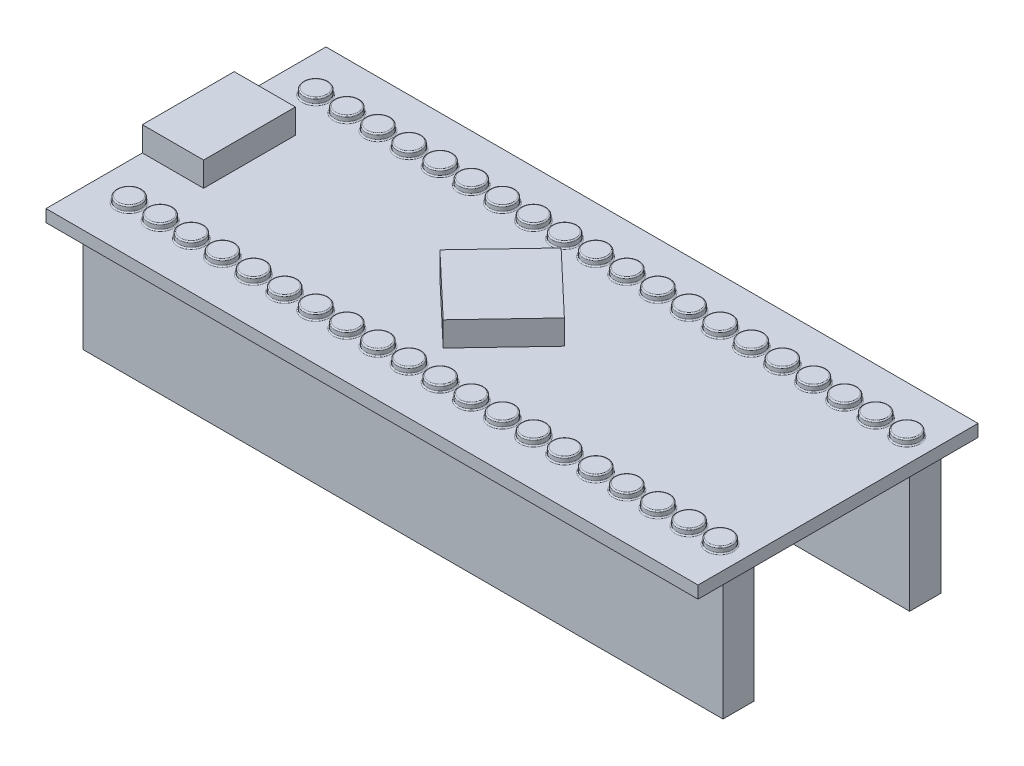
from build123d import *

# Parameters (mm, degrees)
SKETCH1_W                  = 53.24
SKETCH1_H                  = 22.86
BOSS_EXTRUDE1_DEPTH        = 1
SKETCH2_R                  = 1
BOSS_EXTRUDE2_DEPTH        = 0.5
SKETCH3_W                  = 52.24
SKETCH3_H                  = 2.54
BOSS_EXTRUDE3_DEPTH        = 10
LPATTERN1_COUNT            = 20
LPATTERN1_PITCH            = 2.54
FILLET1_R                  = 0.1
FILLET2_R                  = 0.1
FILLET3_R                  = 0.1
LPATTERN2_COUNT            = 2
LPATTERN2_PITCH            = 15.24
LPATTERN2_COPY_1_SKETCH_R  = 1
LPATTERN2_COPY_1_DEPTH     = 0.5
LPATTERN2_COPY_2_SKETCH_R  = 1
LPATTERN2_COPY_2_DEPTH     = 0.5
LPATTERN2_COPY_3_SKETCH_R  = 1
LPATTERN2_COPY_3_DEPTH     = 0.5
LPATTERN2_COPY_4_SKETCH_R  = 1
LPATTERN2_COPY_4_DEPTH     = 0.5
LPATTERN2_COPY_5_SKETCH_R  = 1
LPATTERN2_COPY_5_DEPTH     = 0.5
LPATTERN2_COPY_6_SKETCH_R  = 1
LPATTERN2_COPY_6_DEPTH     = 0.5
LPATTERN2_COPY_7_SKETCH_R  = 1
LPATTERN2_COPY_7_DEPTH     = 0.5
LPATTERN2_COPY_8_SKETCH_R  = 1
LPATTERN2_COPY_8_DEPTH     = 0.5
LPATTERN2_COPY_9_SKETCH_R  = 1
LPATTERN2_COPY_9_DEPTH     = 0.5
LPATTERN2_COPY_10_SKETCH_R = 1
LPATTERN2_COPY_10_DEPTH    = 0.5
LPATTERN2_COPY_11_SKETCH_R = 1
LPATTERN2_COPY_11_DEPTH    = 0.5
LPATTERN2_COPY_12_SKETCH_R = 1
LPATTERN2_COPY_12_DEPTH    = 0.5
LPATTERN2_COPY_13_SKETCH_R = 1
LPATTERN2_COPY_13_DEPTH    = 0.5
LPATTERN2_COPY_14_SKETCH_R = 1
LPATTERN2_COPY_14_DEPTH    = 0.5
LPATTERN2_COPY_15_SKETCH_R = 1
LPATTERN2_COPY_15_DEPTH    = 0.5
LPATTERN2_COPY_16_SKETCH_R = 1
LPATTERN2_COPY_16_DEPTH    = 0.5
LPATTERN2_COPY_17_SKETCH_R = 1
LPATTERN2_COPY_17_DEPTH    = 0.5
LPATTERN2_COPY_18_SKETCH_R = 1
LPATTERN2_COPY_18_DEPTH    = 0.5
LPATTERN2_COPY_19_SKETCH_R = 1
LPATTERN2_COPY_19_DEPTH    = 0.5
FILLET4_R                  = 0.1
SKETCH5_W                  = 5
SKETCH5_H                  = 7.5
BOSS_EXTRUDE4_DEPTH        = 2
BOSS_EXTRUDE5_DEPTH        = 2


with BuildPart() as part:
    # Sketch1 → Boss-Extrude1 (new body)
    with BuildSketch(Plane(origin=(0, 0, 0), x_dir=(1, 0, 0), z_dir=(0, 1, 0))):
        with Locations((26.62, 11.43)):
            Rectangle(SKETCH1_W, SKETCH1_H)
    extrude(amount=BOSS_EXTRUDE1_DEPTH)

    # Sketch2 → Boss-Extrude2 (add)
    with BuildSketch(Plane(origin=(0, 1, 0), x_dir=(1, 0, 0), z_dir=(0, 1, 0))):
        with Locations((2.974226971, 3.81)):
            Circle(SKETCH2_R)
    boss_extrude2 = extrude(amount=BOSS_EXTRUDE2_DEPTH)

    # Sketch3 → Boss-Extrude3 (add)
    with BuildSketch(Plane(origin=(0, 0, 0), x_dir=(-1, 0, 0), z_dir=(0, -1, 0))):
        with Locations((-26.62, 3.81)):
            Rectangle(SKETCH3_W, SKETCH3_H)
        with Locations((-26.62, 19.05)):
            Rectangle(SKETCH3_W, SKETCH3_H)
    extrude(amount=BOSS_EXTRUDE3_DEPTH)

    # LPattern1: Boss-Extrude2 ×20
    with Locations(*[(i * LPATTERN1_PITCH, 0, 0) for i in range(1, LPATTERN1_COUNT)]):
        add(boss_extrude2)

    # Fillet1
    fillet1_edges = [part.edges().sort_by_distance(p)[0] for p in [
        (1.974226971, 1.5, -3.81),
    ]]
    fillet(fillet1_edges, radius=FILLET1_R)

    # Fillet2
    fillet2_edges = [part.edges().sort_by_distance(p)[0] for p in [
        (4.514226971, 1, -3.81),
        (4.514226971, 1.5, -3.81),
        (7.054226971, 1, -3.81),
        (7.054226971, 1.5, -3.81),
        (9.594226971, 1, -3.81),
        (9.594226971, 1.5, -3.81),
        (12.134226971, 1, -3.81),
        (12.134226971, 1.5, -3.81),
        (14.674226971, 1, -3.81),
        (14.674226971, 1.5, -3.81),
        (17.214226971, 1, -3.81),
        (17.214226971, 1.5, -3.81),
        (19.754226971, 1, -3.81),
        (19.754226971, 1.5, -3.81),
        (22.294226971, 1, -3.81),
        (22.294226971, 1.5, -3.81),
        (24.834226971, 1, -3.81),
        (24.834226971, 1.5, -3.81),
        (27.374226971, 1, -3.81),
        (27.374226971, 1.5, -3.81),
        (29.914226971, 1, -3.81),
        (29.914226971, 1.5, -3.81),
        (32.454226971, 1, -3.81),
        (32.454226971, 1.5, -3.81),
        (34.994226971, 1, -3.81),
        (34.994226971, 1.5, -3.81),
        (37.534226971, 1, -3.81),
        (37.534226971, 1.5, -3.81),
        (40.074226971, 1, -3.81),
        (40.074226971, 1.5, -3.81),
        (42.614226971, 1, -3.81),
        (42.614226971, 1.5, -3.81),
        (45.154226971, 1, -3.81),
        (45.154226971, 1.5, -3.81),
        (47.694226971, 1, -3.81),
        (47.694226971, 1.5, -3.81),
        (50.234226971, 1, -3.81),
        (50.234226971, 1.5, -3.81),
    ]]
    fillet(fillet2_edges, radius=FILLET2_R)

    # Fillet3
    fillet3_edges = [part.edges().sort_by_distance(p)[0] for p in [
        (1.974226971, 1, -3.81),
    ]]
    fillet(fillet3_edges, radius=FILLET3_R)

    # LPattern2: Boss-Extrude2 ×2
    with Locations(*[(0, 0, -i * LPATTERN2_PITCH) for i in range(1, LPATTERN2_COUNT)]):
        add(boss_extrude2)

    # LPattern2 copy 1 sketch → LPattern2 copy 1 (add)
    with BuildSketch(Plane(origin=(2.54, 1, -15.24), x_dir=(1, 0, 0), z_dir=(0, 1, 0))):
        with Locations((2.974226971, 3.81)):
            Circle(LPATTERN2_COPY_1_SKETCH_R)
    extrude(amount=LPATTERN2_COPY_1_DEPTH)

    # LPattern2 copy 2 sketch → LPattern2 copy 2 (add)
    with BuildSketch(Plane(origin=(5.08, 1, -15.24), x_dir=(1, 0, 0), z_dir=(0, 1, 0))):
        with Locations((2.974226971, 3.81)):
            Circle(LPATTERN2_COPY_2_SKETCH_R)
    extrude(amount=LPATTERN2_COPY_2_DEPTH)

    # LPattern2 copy 3 sketch → LPattern2 copy 3 (add)
    with BuildSketch(Plane(origin=(7.62, 1, -15.24), x_dir=(1, 0, 0), z_dir=(0, 1, 0))):
        with Locations((2.974226971, 3.81)):
            Circle(LPATTERN2_COPY_3_SKETCH_R)
    extrude(amount=LPATTERN2_COPY_3_DEPTH)

    # LPattern2 copy 4 sketch → LPattern2 copy 4 (add)
    with BuildSketch(Plane(origin=(10.16, 1, -15.24), x_dir=(1, 0, 0), z_dir=(0, 1, 0))):
        with Locations((2.974226971, 3.81)):
            Circle(LPATTERN2_COPY_4_SKETCH_R)
    extrude(amount=LPATTERN2_COPY_4_DEPTH)

    # LPattern2 copy 5 sketch → LPattern2 copy 5 (add)
    with BuildSketch(Plane(origin=(12.7, 1, -15.24), x_dir=(1, 0, 0), z_dir=(0, 1, 0))):
        with Locations((2.974226971, 3.81)):
            Circle(LPATTERN2_COPY_5_SKETCH_R)
    extrude(amount=LPATTERN2_COPY_5_DEPTH)

    # LPattern2 copy 6 sketch → LPattern2 copy 6 (add)
    with BuildSketch(Plane(origin=(15.24, 1, -15.24), x_dir=(1, 0, 0), z_dir=(0, 1, 0))):
        with Locations((2.974226971, 3.81)):
            Circle(LPATTERN2_COPY_6_SKETCH_R)
    extrude(amount=LPATTERN2_COPY_6_DEPTH)

    # LPattern2 copy 7 sketch → LPattern2 copy 7 (add)
    with BuildSketch(Plane(origin=(17.78, 1, -15.24), x_dir=(1, 0, 0), z_dir=(0, 1, 0))):
        with Locations((2.974226971, 3.81)):
            Circle(LPATTERN2_COPY_7_SKETCH_R)
    extrude(amount=LPATTERN2_COPY_7_DEPTH)

    # LPattern2 copy 8 sketch → LPattern2 copy 8 (add)
    with BuildSketch(Plane(origin=(20.32, 1, -15.24), x_dir=(1, 0, 0), z_dir=(0, 1, 0))):
        with Locations((2.974226971, 3.81)):
            Circle(LPATTERN2_COPY_8_SKETCH_R)
    extrude(amount=LPATTERN2_COPY_8_DEPTH)

    # LPattern2 copy 9 sketch → LPattern2 copy 9 (add)
    with BuildSketch(Plane(origin=(22.86, 1, -15.24), x_dir=(1, 0, 0), z_dir=(0, 1, 0))):
        with Locations((2.974226971, 3.81)):
            Circle(LPATTERN2_COPY_9_SKETCH_R)
    extrude(amount=LPATTERN2_COPY_9_DEPTH)

    # LPattern2 copy 10 sketch → LPattern2 copy 10 (add)
    with BuildSketch(Plane(origin=(25.4, 1, -15.24), x_dir=(1, 0, 0), z_dir=(0, 1, 0))):
        with Locations((2.974226971, 3.81)):
            Circle(LPATTERN2_COPY_10_SKETCH_R)
    extrude(amount=LPATTERN2_COPY_10_DEPTH)

    # LPattern2 copy 11 sketch → LPattern2 copy 11 (add)
    with BuildSketch(Plane(origin=(27.94, 1, -15.24), x_dir=(1, 0, 0), z_dir=(0, 1, 0))):
        with Locations((2.974226971, 3.81)):
            Circle(LPATTERN2_COPY_11_SKETCH_R)
    extrude(amount=LPATTERN2_COPY_11_DEPTH)

    # LPattern2 copy 12 sketch → LPattern2 copy 12 (add)
    with BuildSketch(Plane(origin=(30.48, 1, -15.24), x_dir=(1, 0, 0), z_dir=(0, 1, 0))):
        with Locations((2.974226971, 3.81)):
            Circle(LPATTERN2_COPY_12_SKETCH_R)
    extrude(amount=LPATTERN2_COPY_12_DEPTH)

    # LPattern2 copy 13 sketch → LPattern2 copy 13 (add)
    with BuildSketch(Plane(origin=(33.02, 1, -15.24), x_dir=(1, 0, 0), z_dir=(0, 1, 0))):
        with Locations((2.974226971, 3.81)):
            Circle(LPATTERN2_COPY_13_SKETCH_R)
    extrude(amount=LPATTERN2_COPY_13_DEPTH)

    # LPattern2 copy 14 sketch → LPattern2 copy 14 (add)
    with BuildSketch(Plane(origin=(35.56, 1, -15.24), x_dir=(1, 0, 0), z_dir=(0, 1, 0))):
        with Locations((2.974226971, 3.81)):
            Circle(LPATTERN2_COPY_14_SKETCH_R)
    extrude(amount=LPATTERN2_COPY_14_DEPTH)

    # LPattern2 copy 15 sketch → LPattern2 copy 15 (add)
    with BuildSketch(Plane(origin=(38.1, 1, -15.24), x_dir=(1, 0, 0), z_dir=(0, 1, 0))):
        with Locations((2.974226971, 3.81)):
            Circle(LPATTERN2_COPY_15_SKETCH_R)
    extrude(amount=LPATTERN2_COPY_15_DEPTH)

    # LPattern2 copy 16 sketch → LPattern2 copy 16 (add)
    with BuildSketch(Plane(origin=(40.64, 1, -15.24), x_dir=(1, 0, 0), z_dir=(0, 1, 0))):
        with Locations((2.974226971, 3.81)):
            Circle(LPATTERN2_COPY_16_SKETCH_R)
    extrude(amount=LPATTERN2_COPY_16_DEPTH)

    # LPattern2 copy 17 sketch → LPattern2 copy 17 (add)
    with BuildSketch(Plane(origin=(43.18, 1, -15.24), x_dir=(1, 0, 0), z_dir=(0, 1, 0))):
        with Locations((2.974226971, 3.81)):
            Circle(LPATTERN2_COPY_17_SKETCH_R)
    extrude(amount=LPATTERN2_COPY_17_DEPTH)

    # LPattern2 copy 18 sketch → LPattern2 copy 18 (add)
    with BuildSketch(Plane(origin=(45.72, 1, -15.24), x_dir=(1, 0, 0), z_dir=(0, 1, 0))):
        with Locations((2.974226971, 3.81)):
            Circle(LPATTERN2_COPY_18_SKETCH_R)
    extrude(amount=LPATTERN2_COPY_18_DEPTH)

    # LPattern2 copy 19 sketch → LPattern2 copy 19 (add)
    with BuildSketch(Plane(origin=(48.26, 1, -15.24), x_dir=(1, 0, 0), z_dir=(0, 1, 0))):
        with Locations((2.974226971, 3.81)):
            Circle(LPATTERN2_COPY_19_SKETCH_R)
    extrude(amount=LPATTERN2_COPY_19_DEPTH)

    # Fillet4
    fillet4_edges = [part.edges().sort_by_distance(p)[0] for p in [
        (1.974226971, 1, -19.05),
        (1.974226971, 1.5, -19.05),
        (4.514226971, 1, -19.05),
        (4.514226971, 1.5, -19.05),
        (7.054226971, 1, -19.05),
        (7.054226971, 1.5, -19.05),
        (9.594226971, 1, -19.05),
        (9.594226971, 1.5, -19.05),
        (12.134226971, 1, -19.05),
        (12.134226971, 1.5, -19.05),
        (14.674226971, 1, -19.05),
        (14.674226971, 1.5, -19.05),
        (17.214226971, 1, -19.05),
        (17.214226971, 1.5, -19.05),
        (19.754226971, 1, -19.05),
        (19.754226971, 1.5, -19.05),
        (22.294226971, 1, -19.05),
        (22.294226971, 1.5, -19.05),
        (24.834226971, 1, -19.05),
        (24.834226971, 1.5, -19.05),
        (27.374226971, 1, -19.05),
        (27.374226971, 1.5, -19.05),
        (29.914226971, 1, -19.05),
        (29.914226971, 1.5, -19.05),
        (32.454226971, 1, -19.05),
        (32.454226971, 1.5, -19.05),
        (34.994226971, 1, -19.05),
        (34.994226971, 1.5, -19.05),
        (37.534226971, 1, -19.05),
        (37.534226971, 1.5, -19.05),
        (40.074226971, 1, -19.05),
        (40.074226971, 1.5, -19.05),
        (42.614226971, 1, -19.05),
        (42.614226971, 1.5, -19.05),
        (45.154226971, 1, -19.05),
        (45.154226971, 1.5, -19.05),
        (47.694226971, 1, -19.05),
        (47.694226971, 1.5, -19.05),
        (50.234226971, 1, -19.05),
        (50.234226971, 1.5, -19.05),
        (26.62, 0, -20.32),
    ]]
    fillet(fillet4_edges, radius=FILLET4_R)

    # Sketch6 → Boss-Extrude5 (add)
    with BuildSketch(Plane(origin=(0, 1, 0), x_dir=(1, 0, 0), z_dir=(0, 1, 0))):
        Polygon((25.815068766, 16.245068766), (21, 11.164211282), (26.080857484, 6.349142516), (30.895926251, 11.43), align=None)
    extrude(amount=BOSS_EXTRUDE5_DEPTH)


with BuildPart() as body_2:
    # Sketch5 → Boss-Extrude4 (new body)
    with BuildSketch(Plane(origin=(0, 1, 0), x_dir=(1, 0, 0), z_dir=(0, 1, 0))):
        with Locations((2.5, 11.616551948)):
            Rectangle(SKETCH5_W, SKETCH5_H)
    extrude(amount=BOSS_EXTRUDE4_DEPTH)


solid = Compound([part.part, body_2.part])
